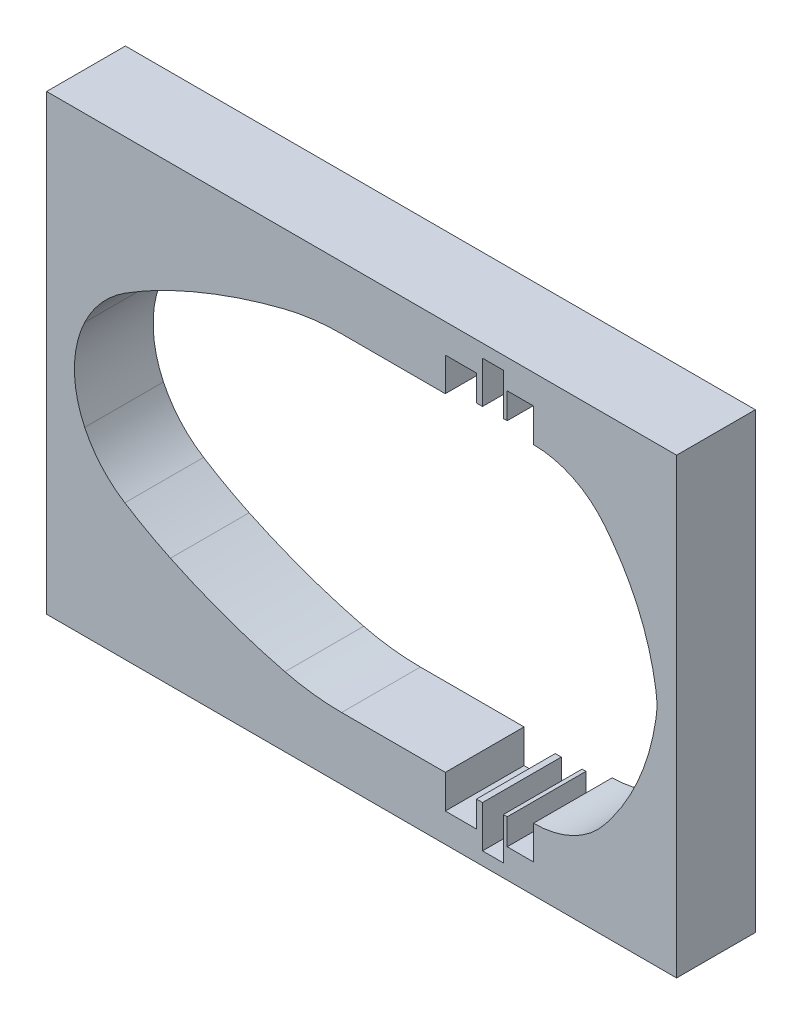
from build123d import *

# Parameters (mm, degrees)
SKETCH_4_W          = 160
SKETCH_4_H          = 115
EXTRUDE_1_DEPTH     = 20
CUT_EXTRUDE_1_DEPTH = 20
SKETCH_16_R         = 5.5
CUT_EXTRUDE_2_DEPTH = 15


with BuildPart() as part:
    # 草圖4 → 填料-伸長1 (new body)
    with BuildSketch(Plane.XY):
        with Locations((14.659712787, 72.59909222)):
            Rectangle(SKETCH_4_W, SKETCH_4_H)
    extrude(amount=EXTRUDE_1_DEPTH)

    # 草圖2 → 除料-伸長1 (cut)
    with BuildSketch(Plane.XY):
        with BuildLine():
            Line((9.582154386, 114.239387395), (32.639572719, 114.239387395))
            Line((32.639572719, 114.239387395), (35.911975242, 114.239387395))
            Line((35.911975242, 114.239387395), (35.911975242, 122.748829131))
            Line((35.911975242, 122.748829131), (43.825042281, 122.748829131))
            Line((43.825042281, 122.748829131), (43.825042281, 116.150572029))
            Line((43.825042281, 116.150572029), (45.365452665, 116.150572029))
            Line((45.365452665, 116.150572029), (45.365452665, 126.787374199))
            Line((45.365452665, 126.787374199), (50.650153823, 126.787374199))
            Line((50.650153823, 126.787374199), (50.650153823, 116.150572029))
            Line((50.650153823, 116.150572029), (51.63260176, 116.150572029))
            Line((51.63260176, 116.150572029), (51.63260176, 122.748829131))
            Line((51.63260176, 122.748829131), (58.302252446, 122.748829131))
            Line((58.302252446, 122.748829131), (58.302252446, 114.239387395))
            ThreePointArc((58.302252446, 114.239387395), (68.354977159, 111.933757574), (76.3981894, 105.477757274))
            ThreePointArc((76.3981894, 105.477757274), (77.386875553, 104.202213525), (78.350890948, 102.907923572))
            ThreePointArc((78.350890948, 102.907923572), (85.469179447, 90.183153699), (89.343429579, 76.126838912))
            Line((89.343429579, 76.126838912), (89.450916797, 75.407862922))
            ThreePointArc((89.450916797, 75.407862922), (89.659712787, 72.59909222), (89.450916797, 69.790321519))
            Line((89.450916797, 69.790321519), (89.343429579, 69.071345528))
            ThreePointArc((89.343429579, 69.071345528), (85.469179447, 55.015030741), (78.350890948, 42.290260868))
            ThreePointArc((78.350890948, 42.290260868), (77.386875553, 40.995970915), (76.3981894, 39.720427166))
            ThreePointArc((76.3981894, 39.720427166), (68.354977159, 33.264426866), (58.302252446, 30.958797045))
            Line((58.302252446, 30.958797045), (58.302252446, 22.449355309))
            Line((58.302252446, 22.449355309), (51.63260176, 22.449355309))
            Line((51.63260176, 22.449355309), (51.63260176, 29.047612411))
            Line((51.63260176, 29.047612411), (50.650153823, 29.047612411))
            Line((50.650153823, 29.047612411), (50.650153823, 18.410810241))
            Line((50.650153823, 18.410810241), (45.365452665, 18.410810241))
            Line((45.365452665, 18.410810241), (45.365452665, 29.047612411))
            Line((45.365452665, 29.047612411), (43.825042281, 29.047612411))
            Line((43.825042281, 29.047612411), (43.825042281, 22.449355309))
            Line((43.825042281, 22.449355309), (35.911975242, 22.449355309))
            Line((35.911975242, 22.449355309), (35.911975242, 30.958797045))
            Line((35.911975242, 30.958797045), (32.639572719, 30.958797045))
            Line((32.639572719, 30.958797045), (9.582154386, 30.958797045))
            ThreePointArc((9.582154386, 30.958797045), (2.328045496, 31.402381927), (-4.817967678, 32.726526576))
            ThreePointArc((-4.817967678, 32.726526576), (-19.619782039, 37.212171907), (-33.900352311, 43.151871824))
            ThreePointArc((-33.900352311, 43.151871824), (-39.787433986, 46.173940455), (-45.481740166, 49.545217155))
            ThreePointArc((-45.481740166, 49.545217155), (-51.391366265, 54.573313812), (-55.677619443, 61.041193705))
            ThreePointArc((-55.677619443, 61.041193705), (-58.292337425, 72.59909222), (-55.677619443, 84.156990735))
            ThreePointArc((-55.677619443, 84.156990735), (-51.391366265, 90.624870628), (-45.481740166, 95.652967285))
            ThreePointArc((-45.481740166, 95.652967285), (-39.787433986, 99.024243985), (-33.900352311, 102.046312617))
            ThreePointArc((-33.900352311, 102.046312617), (-19.619782039, 107.986012534), (-4.817967678, 112.471657865))
            ThreePointArc((-4.817967678, 112.471657865), (2.328045496, 113.795802514), (9.582154386, 114.239387395))
        make_face()
    extrude(amount=CUT_EXTRUDE_1_DEPTH, mode=Mode.SUBTRACT)

    # 草圖16 → 除料-伸長2 (cut)
    with BuildSketch(Plane(origin=(-66.2, 0, 0), x_dir=(0, 0, -1), z_dir=(1, 0, 0))):
        with Locations((-10, 120.09909222)):
            Circle(SKETCH_16_R)
        with Locations((-10, 105.09909222)):
            Circle(SKETCH_16_R)
        with Locations((-10, 40.09909222)):
            Circle(SKETCH_16_R)
        with Locations((-10, 25.09909222)):
            Circle(SKETCH_16_R)
    extrude(amount=CUT_EXTRUDE_2_DEPTH, mode=Mode.SUBTRACT)


solid = part.part
